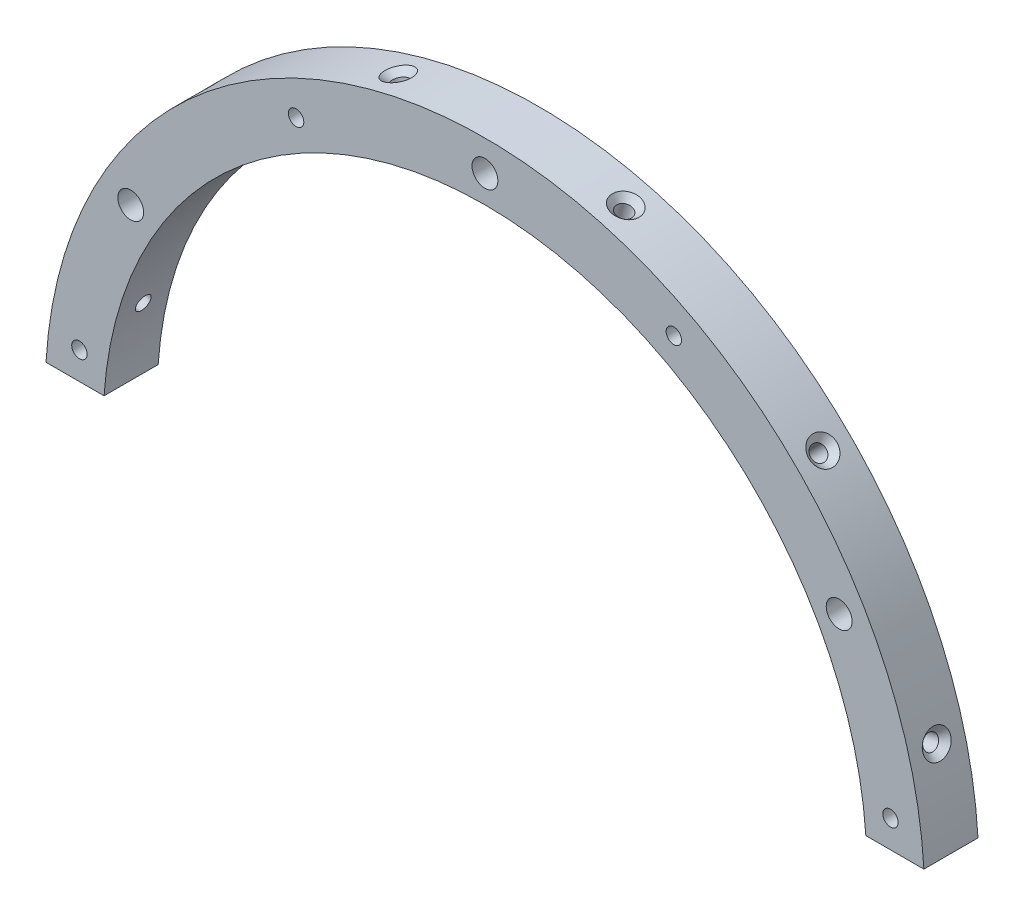
from build123d import *

# Parameters (mm, degrees)
BOSS_EXTRUDE1_DEPTH              = 3.96875
CIRPATTERN1_COUNT                = 6
CIRPATTERN1_ANGLE                = 150
F_4_40_TAPPED_HOLE3_D            = 2.2606
F_4_40_TAPPED_HOLE3_CSINK_D      = 4.1148
F_4_40_TAPPED_HOLE3_CSINK_ANGLE  = 90
CIRPATTERN2_COUNT                = 4
CIRPATTERN2_ANGLE                = 165
F_10_24_TAPPED_HOLE1_D           = 3.7973
F_10_24_TAPPED_HOLE1_CSINK_D     = 6.096
F_10_24_TAPPED_HOLE1_CSINK_ANGLE = 90
CIRPATTERN3_COUNT                = 3
CIRPATTERN3_ANGLE                = 120


with BuildPart() as part:
    # Sketch1 → Boss-Extrude1 (new body, symmetric)
    with BuildSketch(Plane.XY):
        with BuildLine():
            Line((-64.387964714, 3.8), (-55.87092267, 3.8))
            ThreePointArc((-55.87092267, 3.8), (0, 56), (55.87092267, 3.8))
            Line((55.87092267, 3.8), (64.387964714, 3.8))
            ThreePointArc((64.387964714, 3.8), (0, 64.5), (-64.387964714, 3.8))
        make_face()
    extrude(amount=BOSS_EXTRUDE1_DEPTH, both=True)

    # Sketch3 → #4-40 Tapped Hole2 (revolve, cut)
    with BuildSketch(Plane(origin=(62.302215796, 16.693828409, 0), x_dir=(-0.258819045, 0.965925826, 0), z_dir=(0, 0, 1))):
        Polygon((0, 0), (0, 9.549152758), (1.1303, 8.87), (1.1303, 0.9271), (2.0574, 0), align=None)
    f_4_40_tapped_hole2 = revolve(axis=Axis((68.435844793, 18.337329346, 0), (-0.965925826, -0.258819045, 0)), mode=Mode.SUBTRACT)

    # CirPattern1: #4-40 Tapped Hole2 ×6 about axis
    cirpattern1_axis = Axis((0, 0, 3.96875), (0, 0, 1))
    for i in range(1, CIRPATTERN1_COUNT):
        add(f_4_40_tapped_hole2.rotate(cirpattern1_axis, i * CIRPATTERN1_ANGLE / (CIRPATTERN1_COUNT - 1)), mode=Mode.SUBTRACT)

    # #4-40 Tapped Hole3 (through all)
    with Locations(Plane(origin=(0, 0, -3.96875), x_dir=(-1, 0, 0), z_dir=(0, 0, -1))):
        with Locations((-59.486691682, 7.831571533)):
            f_4_40_tapped_hole3 = CounterSinkHole(F_4_40_TAPPED_HOLE3_D / 2, F_4_40_TAPPED_HOLE3_CSINK_D / 2, counter_sink_angle=F_4_40_TAPPED_HOLE3_CSINK_ANGLE)

    # CirPattern2: #4-40 Tapped Hole3 ×4 about axis
    cirpattern2_axis = Axis((0, 0, 0), (0, 0, 1))
    for i in range(1, CIRPATTERN2_COUNT):
        add(f_4_40_tapped_hole3.rotate(cirpattern2_axis, i * CIRPATTERN2_ANGLE / (CIRPATTERN2_COUNT - 1)), mode=Mode.SUBTRACT)

    # #10-24 Tapped Hole1 (through all)
    with Locations(Plane(origin=(0, 0, -3.96875), x_dir=(-1, 0, 0), z_dir=(0, 0, -1))):
        with Locations((-51.961524227, 30)):
            f_10_24_tapped_hole1 = CounterSinkHole(F_10_24_TAPPED_HOLE1_D / 2, F_10_24_TAPPED_HOLE1_CSINK_D / 2, counter_sink_angle=F_10_24_TAPPED_HOLE1_CSINK_ANGLE)

    # CirPattern3: #10-24 Tapped Hole1 ×3 about axis
    cirpattern3_axis = Axis((0, 0, 0), (0, 0, 1))
    for i in range(1, CIRPATTERN3_COUNT):
        add(f_10_24_tapped_hole1.rotate(cirpattern3_axis, i * CIRPATTERN3_ANGLE / (CIRPATTERN3_COUNT - 1)), mode=Mode.SUBTRACT)


solid = part.part
